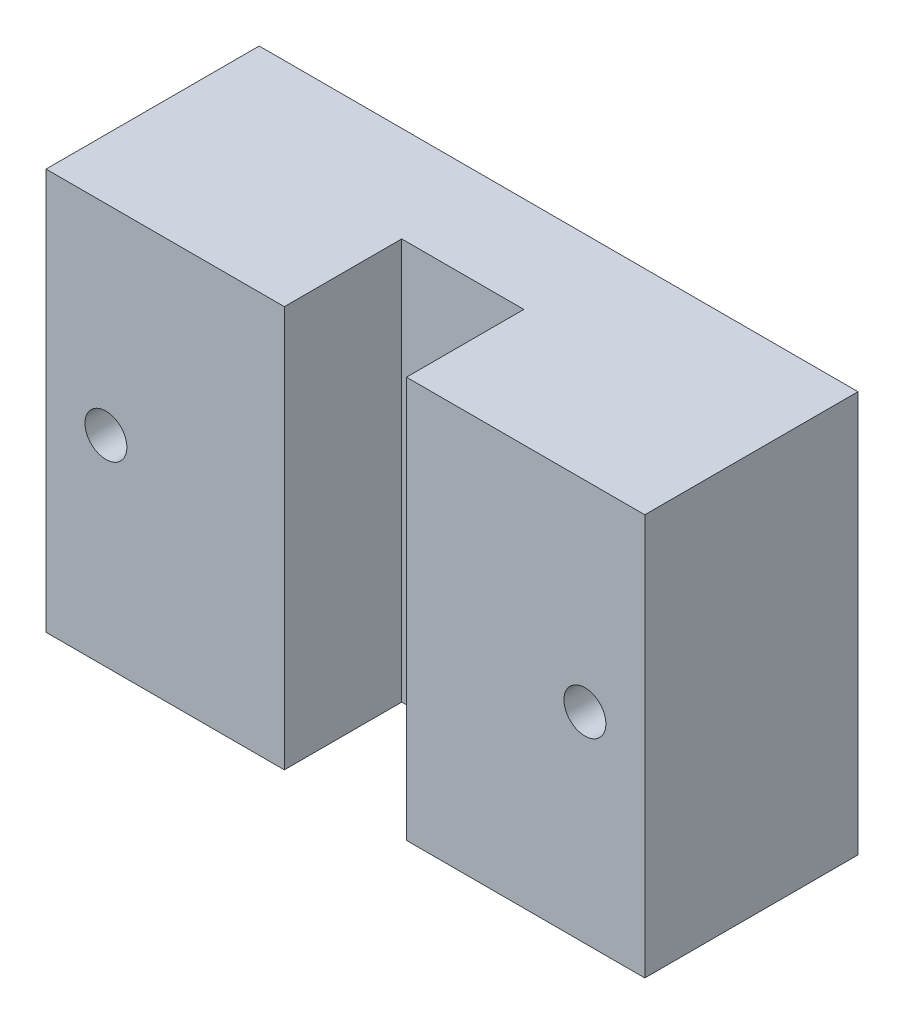
from build123d import *

# Parameters (mm, degrees)
SKETCH2_W           = 50
SKETCH2_H           = 33.5
SKETCH2_R           = 1.75
BOSS_EXTRUDE1_DEPTH = 8
BOSS_EXTRUDE2_DEPTH = 33.5
SKETCH6_R           = 1.75
CUT_EXTRUDE1_DEPTH  = 18.8


with BuildPart() as part:
    # Sketch2 → Boss-Extrude1 (new body)
    with BuildSketch(Plane.XY):
        Rectangle(SKETCH2_W, SKETCH2_H)
        with Locations((-20, 0)):
            Circle(SKETCH2_R, mode=Mode.SUBTRACT)
        with Locations((20, 0)):
            Circle(SKETCH2_R, mode=Mode.SUBTRACT)
    extrude(amount=BOSS_EXTRUDE1_DEPTH)

    # Sketch5 → Boss-Extrude2 (add)
    with BuildSketch(Plane.XZ.offset(16.75)):
        with BuildLine():
            Line((-25, 8), (-25, 17.8))
            Line((-25, 17.8), (-5.1, 17.8))
            Line((-5.1, 17.8), (-5.1, 8))
            Line((-5.1, 8), (5.1, 8))
            Line((5.1, 8), (5.1, 17.8))
            Line((5.1, 17.8), (25, 17.8))
            Line((25, 17.8), (25, 8))
            ThreePointArc((25, 8), (0, 0), (-25, 8))
        make_face()
    extrude(amount=-BOSS_EXTRUDE2_DEPTH)

    # Sketch6 → Cut-Extrude1 (cut, through all)
    with BuildSketch(Plane(origin=(0, 0, 0), x_dir=(-1, 0, 0), z_dir=(0, 0, -1))):
        with Locations((20, 0)):
            Circle(SKETCH6_R)
        with Locations((-20, 0)):
            Circle(SKETCH6_R)
    extrude(amount=-CUT_EXTRUDE1_DEPTH, mode=Mode.SUBTRACT)


solid = part.part
